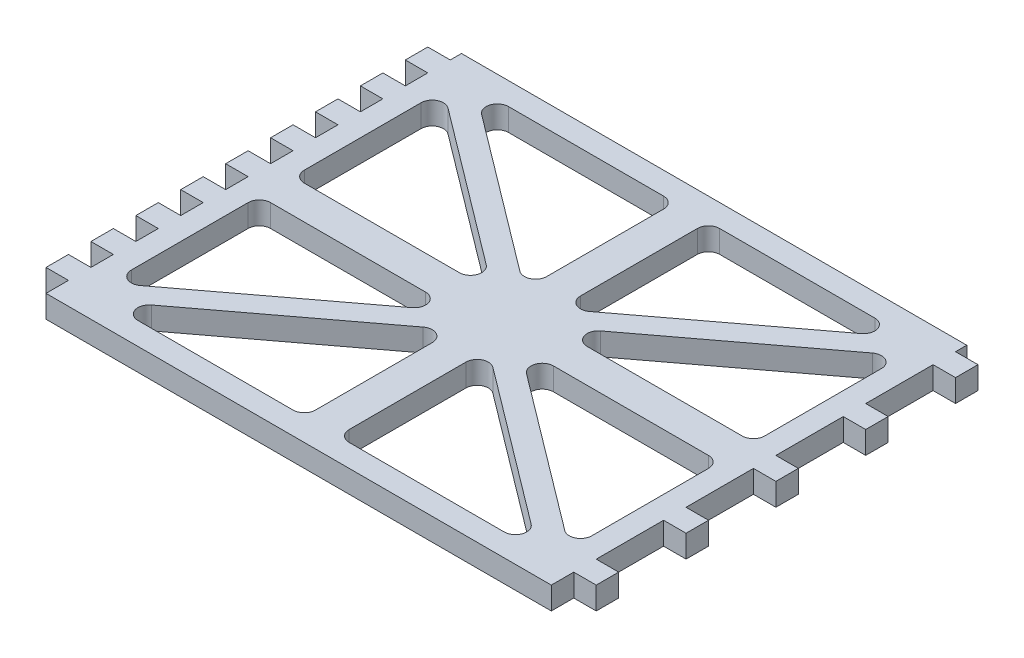
from build123d import *

# Parameters (mm, degrees)
BOSS_EXTRUDE1_DEPTH = 4
CUT_EXTRUDE1_DEPTH  = 10


with BuildPart() as part:
    # Sketch1 → Boss-Extrude1 (new body)
    with BuildSketch(Plane(origin=(0, 0, 0), x_dir=(1, 0, 0), z_dir=(0, 1, 0))):
        Polygon((-10.4, 13.35), (-10.4, 11.35), (-14.4, 11.35), (-14.4, 7.35), (-10.4, 7.35), (-10.4, 3.35), (-14.4, 3.35), (-14.4, -0.65), (-10.4, -0.65), (-10.4, -4.65), (-14.4, -4.65), (-14.4, -8.65), (-10.4, -8.65), (-10.4, -12.65), (-14.4, -12.65), (-14.4, -16.65), (-10.4, -16.65), (-10.4, -20.65), (-14.4, -20.65), (-14.4, -24.65), (-10.4, -24.65), (-10.4, -28.65), (-14.4, -28.65), (-14.4, -32.65), (-10.4, -32.65), (-10.4, -36.65), (-14.4, -36.65), (-14.4, -40.65), (-10.4, -40.65), (-10.4, -44.65), (-14.4, -44.65), (-14.4, -48.65), (-10.4, -48.65), (-10.4, -52.65), (-14.4, -52.65), (-14.4, -56.65), (-10.4, -56.65), (-10.4, -60.65), (79.6, -60.65), (79.6, -56.65), (83.6, -56.65), (83.6, -52.65), (79.6, -52.65), (79.6, -40.65), (83.6, -40.65), (83.6, -36.65), (79.6, -36.65), (79.6, -24.65), (83.6, -24.65), (83.6, -20.65), (79.6, -20.65), (79.6, -8.65), (83.6, -8.65), (83.6, -4.65), (79.6, -4.65), (79.6, 7.35), (83.6, 7.35), (83.6, 11.35), (79.6, 11.35), (79.6, 13.35), align=None)
    extrude(amount=-BOSS_EXTRUDE1_DEPTH)

    # Sketch2 → Cut-Extrude1 (cut)
    with BuildSketch(Plane(origin=(0, 0, 0), x_dir=(1, 0, 0), z_dir=(0, 1, 0))):
        with BuildLine():
            Line((1.986692504, 9.35), (29.6, 9.35))
            ThreePointArc((29.6, 9.35), (31.014213562, 8.764213562), (31.6, 7.35))
            Line((31.6, 7.35), (31.6, -13.44487837))
            ThreePointArc((31.6, -13.44487837), (30.492669396, -15.23461057), (28.39685865, -15.042517532))
            Line((28.39685865, -15.042517532), (0.783551154, 5.752360838))
            ThreePointArc((0.783551154, 5.752360838), (0.089948145, 7.984319192), (1.986692504, 9.35))
        make_face()
        with BuildLine():
            ThreePointArc((-6.4, 2.14487837), (-5.292669396, 3.93461057), (-3.19685865, 3.742517532))
            Line((-3.19685865, 3.742517532), (24.416448846, -17.052360838))
            ThreePointArc((24.416448846, -17.052360838), (25.110051855, -19.284319192), (23.213307496, -20.65))
            Line((23.213307496, -20.65), (-4.4, -20.65))
            ThreePointArc((-4.4, -20.65), (-5.814213562, -20.064213562), (-6.4, -18.65))
            Line((-6.4, -18.65), (-6.4, 2.14487837))
        make_face()
        with BuildLine():
            Line((37.6, 7.35), (37.6, -13.44487837))
            ThreePointArc((37.6, -13.44487837), (38.707330604, -15.23461057), (40.80314135, -15.042517532))
            Line((40.80314135, -15.042517532), (68.416448846, 5.752360838))
            ThreePointArc((68.416448846, 5.752360838), (69.110051855, 7.984319192), (67.213307496, 9.35))
            Line((67.213307496, 9.35), (39.6, 9.35))
            ThreePointArc((39.6, 9.35), (38.185786438, 8.764213562), (37.6, 7.35))
        make_face()
        with BuildLine():
            ThreePointArc((75.6, -18.65), (75.014213562, -20.064213562), (73.6, -20.65))
            Line((73.6, -20.65), (45.986692504, -20.65))
            ThreePointArc((45.986692504, -20.65), (44.089948145, -19.284319192), (44.783551154, -17.052360838))
            Line((44.783551154, -17.052360838), (72.39685865, 3.742517532))
            ThreePointArc((72.39685865, 3.742517532), (74.492669396, 3.93461057), (75.6, 2.14487837))
            Line((75.6, 2.14487837), (75.6, -18.65))
        make_face()
        with BuildLine():
            ThreePointArc((75.6, -49.44487837), (74.492669396, -51.23461057), (72.39685865, -51.042517532))
            Line((72.39685865, -51.042517532), (44.783551154, -30.247639162))
            ThreePointArc((44.783551154, -30.247639162), (44.089948145, -28.015680808), (45.986692504, -26.65))
            Line((45.986692504, -26.65), (73.6, -26.65))
            ThreePointArc((73.6, -26.65), (75.014213562, -27.235786438), (75.6, -28.65))
            Line((75.6, -28.65), (75.6, -49.44487837))
        make_face()
        with BuildLine():
            Line((67.213307496, -56.65), (39.6, -56.65))
            ThreePointArc((39.6, -56.65), (38.185786438, -56.064213562), (37.6, -54.65))
            Line((37.6, -54.65), (37.6, -33.85512163))
            ThreePointArc((37.6, -33.85512163), (38.707330604, -32.06538943), (40.80314135, -32.257482468))
            Line((40.80314135, -32.257482468), (68.416448846, -53.052360838))
            ThreePointArc((68.416448846, -53.052360838), (69.110051855, -55.284319192), (67.213307496, -56.65))
        make_face()
        with BuildLine():
            Line((31.6, -54.65), (31.6, -33.85512163))
            ThreePointArc((31.6, -33.85512163), (30.492669396, -32.06538943), (28.39685865, -32.257482468))
            Line((28.39685865, -32.257482468), (0.783551154, -53.052360838))
            ThreePointArc((0.783551154, -53.052360838), (0.089948145, -55.284319192), (1.986692504, -56.65))
            Line((1.986692504, -56.65), (29.6, -56.65))
            ThreePointArc((29.6, -56.65), (31.014213562, -56.064213562), (31.6, -54.65))
        make_face()
        with BuildLine():
            ThreePointArc((-6.4, -28.65), (-5.814213562, -27.235786438), (-4.4, -26.65))
            Line((-4.4, -26.65), (23.213307496, -26.65))
            ThreePointArc((23.213307496, -26.65), (25.110051855, -28.015680808), (24.416448846, -30.247639162))
            Line((24.416448846, -30.247639162), (-3.19685865, -51.042517532))
            ThreePointArc((-3.19685865, -51.042517532), (-5.292669396, -51.23461057), (-6.4, -49.44487837))
            Line((-6.4, -49.44487837), (-6.4, -28.65))
        make_face()
    extrude(amount=-CUT_EXTRUDE1_DEPTH, mode=Mode.SUBTRACT)


solid = part.part
